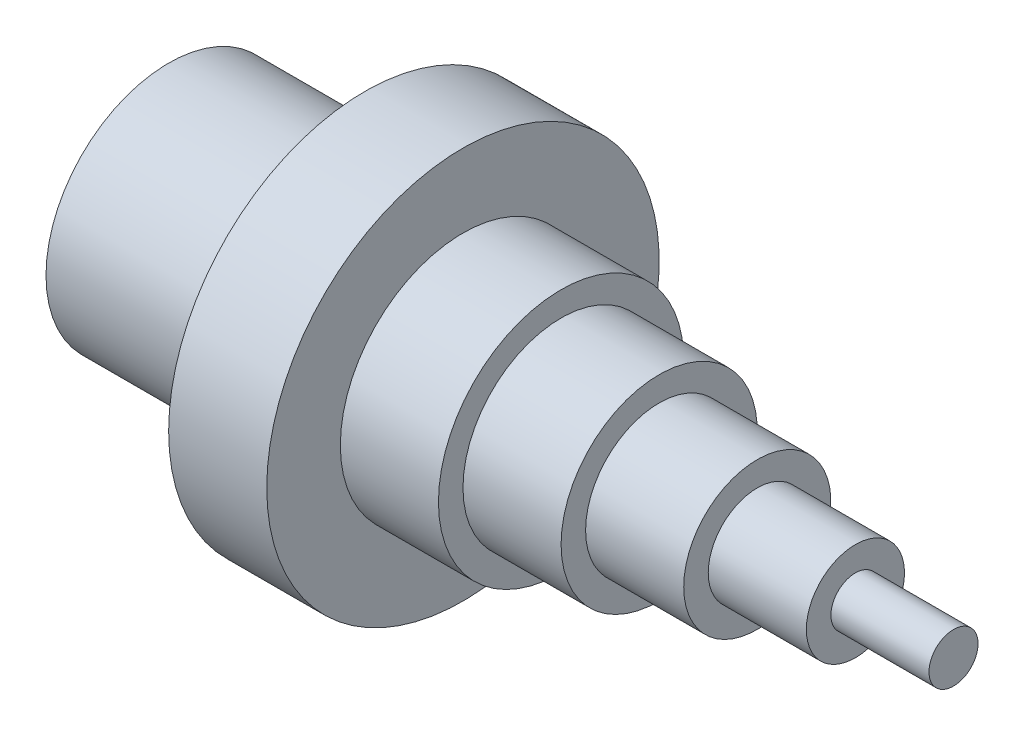
from build123d import *


with BuildPart() as part:
    # Sketch1 → Revolve1 (revolve)
    with BuildSketch(Plane.XY, mode=Mode.PRIVATE) as revolve1_sk:
        Polygon((0, 0), (0, 25), (40, 25), (40, 40), (60, 40), (60, 25), (80, 25), (80, 20), (100, 20), (100, 15), (120, 15), (120, 10), (140, 10), (140, 5), (160, 5), (160, 0), align=None)
    revolve(revolve1_sk.sketch.rotate(Axis((0, 0, 0), (1, 0, 0)), 90), axis=Axis((0, 0, 0), (1, 0, 0)))  # turned: the seam where the file's is


solid = part.part
